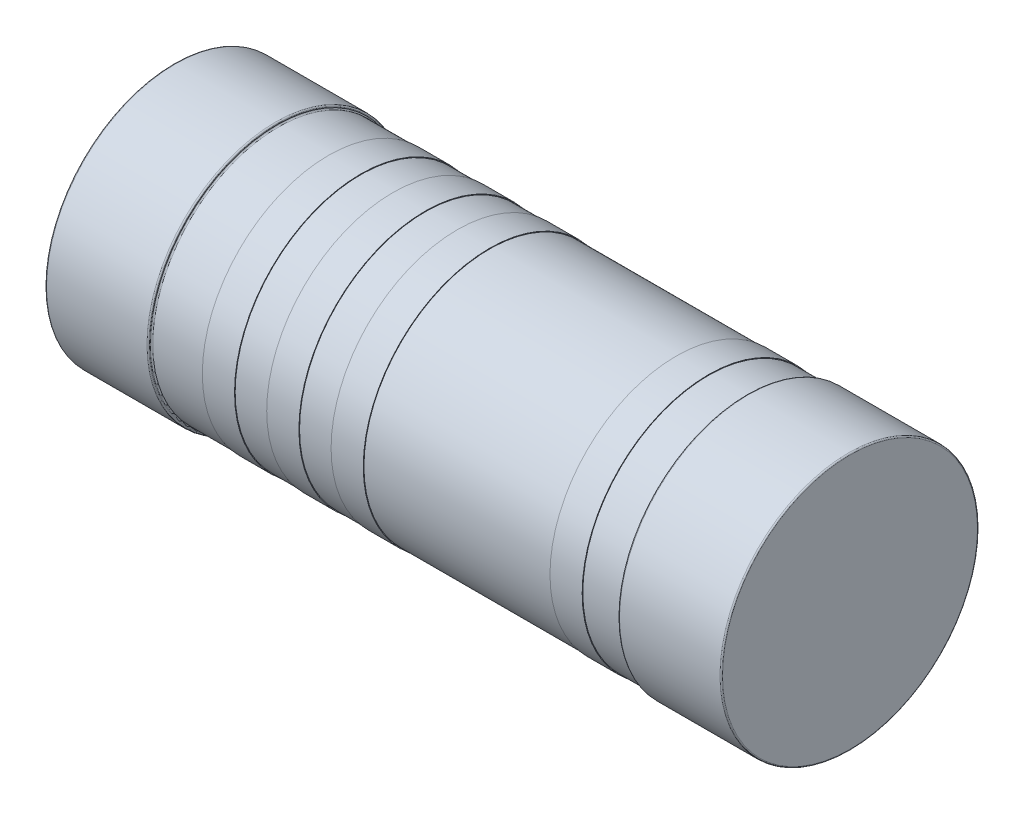
from build123d import *


with BuildPart() as part:
    # Sketch1 → Revolve1 (revolve)
    with BuildSketch(Plane.XY):
        with BuildLine():
            Line((-5.25, 2), (5.25, 2))
            Line((5.25, 2), (5.25, 0.02))
            ThreePointArc((5.25, 0.02), (5.244142136, 0.005857864), (5.23, 0))
            Line((5.23, 0), (3.67, 0))
            ThreePointArc((3.67, 0), (3.655857864, 0.005857864), (3.65, 0.02))
            Line((3.65, 0.02), (3.65, 0.03))
            ThreePointArc((3.65, 0.03), (3.644142136, 0.044142136), (3.63, 0.05))
            Line((3.63, 0.05), (3.05, 0.05))
            Line((3.05, 0.05), (3.05, 0.04))
            Line((3.05, 0.04), (2.55, 0.04))
            Line((2.55, 0.04), (2.55, 0.05))
            Line((2.55, 0.05), (-0.35, 0.05))
            Line((-0.35, 0.05), (-0.35, 0.04))
            Line((-0.35, 0.04), (-0.85, 0.04))
            Line((-0.85, 0.04), (-0.85, 0.05))
            Line((-0.85, 0.05), (-1.35, 0.05))
            Line((-1.35, 0.05), (-1.35, 0.04))
            Line((-1.35, 0.04), (-1.85, 0.04))
            Line((-1.85, 0.04), (-1.85, 0.05))
            Line((-1.85, 0.05), (-2.35, 0.05))
            Line((-2.35, 0.05), (-2.35, 0.04))
            Line((-2.35, 0.04), (-2.85, 0.04))
            Line((-2.85, 0.04), (-2.85, 0.05))
            Line((-2.85, 0.05), (-3.63, 0.05))
            ThreePointArc((-3.63, 0.05), (-3.644142136, 0.044142136), (-3.65, 0.03))
            Line((-3.65, 0.03), (-3.65, 0.02))
            ThreePointArc((-3.65, 0.02), (-3.655857864, 0.005857864), (-3.67, 0))
            Line((-3.67, 0), (-5.23, 0))
            ThreePointArc((-5.23, 0), (-5.244142136, 0.005857864), (-5.25, 0.02))
            Line((-5.25, 0.02), (-5.25, 2))
        make_face()
    revolve(axis=Axis((-5.25, 2, 0), (1, 0, 0)))


solid = part.part
